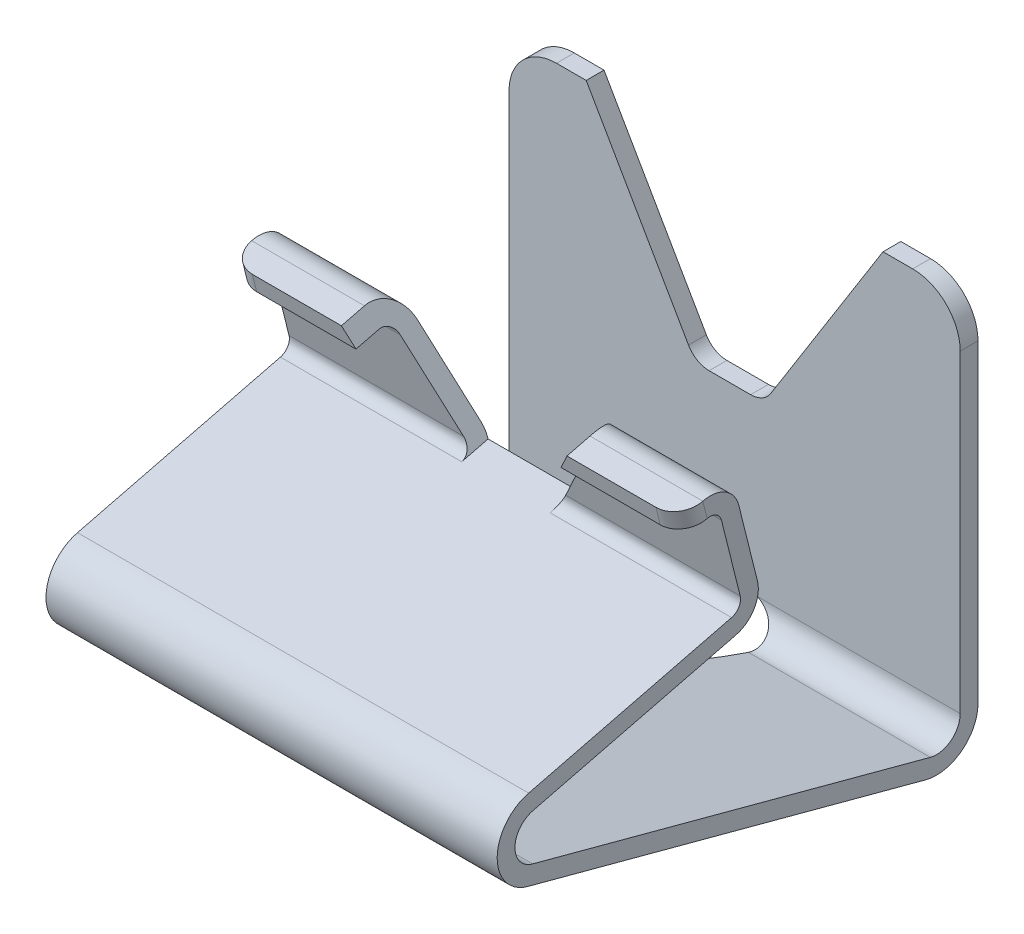
from build123d import *

# Parameters (mm, degrees)
BOSS_EXTRUDE1_DEPTH     = 38
FILLET1_R               = 4
FILLET2_R               = 8
CUT_EXTRUDE1_DEPTH      = 1
CUT_EXTRUDE1_DEPTH_BACK = 13
FILLET3_R               = 4
SKETCH4_R               = 8
CUT_EXTRUDE4_DEPTH      = 82.000266539
CUT_EXTRUDE5_DEPTH      = 51.051633202
CUT_EXTRUDE5_DEPTH_BACK = 45.963614062


with BuildPart() as part:
    # Sketch1 → Boss-Extrude1 (new body, symmetric)
    with BuildSketch(Plane.YZ):
        with BuildLine():
            Line((9.12257761, 0), (70, 0))
            Line((70, 0), (70, 3))
            Line((70, 3), (9.12257761, 3))
            ThreePointArc((9.12257761, 3), (5.949164249, 4.564954284), (5.258874305, 8.03527618))
            Line((5.258874305, 8.03527618), (23.211541616, 75.035542719))
            ThreePointArc((23.211541616, 75.035542719), (27.110151064, 78.000114231), (30.956427827, 74.967954121))
            Line((30.956427827, 74.967954121), (39.477634655, 40.791260242))
            ThreePointArc((39.477634655, 40.791260242), (41.753922912, 37.715033217), (45.538722765, 37.149391089))
            Line((45.538722765, 37.149391089), (58.152567206, 40.294375732))
            ThreePointArc((58.152567206, 40.294375732), (61.228794232, 42.570663989), (61.79443636, 46.355463841))
            Line((61.79443636, 46.355463841), (60.826748777, 50.236646746))
            Line((60.826748777, 50.236646746), (57.915861598, 49.510881059))
            Line((57.915861598, 49.510881059), (58.883549181, 45.629698154))
            ThreePointArc((58.883549181, 45.629698154), (58.65729233, 44.115778213), (57.426801519, 43.205262911))
            Line((57.426801519, 43.205262911), (44.812957078, 40.060278268))
            ThreePointArc((44.812957078, 40.060278268), (43.299037137, 40.286535119), (42.388521834, 41.517025929))
            Line((42.388521834, 41.517025929), (33.867315005, 75.693719808))
            ThreePointArc((33.867315005, 75.693719808), (27.13633067, 81), (20.313764138, 75.811999854))
            Line((20.313764138, 75.811999854), (2.361096826, 8.811733316))
            ThreePointArc((2.361096826, 8.811733316), (3.569104228, 2.738669997), (9.12257761, 0))
        make_face()
    extrude(amount=BOSS_EXTRUDE1_DEPTH, both=True)

    # Fillet1
    fillet1_edges = [part.edges().sort_by_distance(p)[0] for p in [
        (-38, 59.371305188, 49.873763903),
        (38, 59.371305188, 49.873763903),
    ]]
    fillet(fillet1_edges, radius=FILLET1_R)

    # Fillet2
    fillet2_edges = [part.edges().sort_by_distance(p)[0] for p in [
        (-38, 70, 1.5),
        (38, 70, 1.5),
    ]]
    fillet(fillet2_edges, radius=FILLET2_R)

    # Sketch2 → Cut-Extrude1 (cut, two sides)
    with BuildSketch(Plane(origin=(0, 0, 0), x_dir=(1, 0, 0), z_dir=(0, 0, -1))) as cut_extrude1_sk:
        Polygon((-25, -70), (-6.612779769, -38), (4.912194323, -38), (25, -70), align=None)
    extrude(amount=CUT_EXTRUDE1_DEPTH, mode=Mode.SUBTRACT)
    extrude(cut_extrude1_sk.sketch, amount=-CUT_EXTRUDE1_DEPTH_BACK, mode=Mode.SUBTRACT)

    # Fillet3
    fillet3_edges = [part.edges().sort_by_distance(p)[0] for p in [
        (4.912194323, 38, 1.5),
        (-6.612779769, 38, 1.5),
    ]]
    fillet(fillet3_edges, radius=FILLET3_R)

    # Sketch4 → Cut-Extrude4 (cut, through all)
    with BuildSketch(Plane(origin=(0, 0, 0), x_dir=(1, 0, 0), z_dir=(0, 0, -1))):
        with Locations((0, -2.12257761)):
            Circle(SKETCH4_R)
    extrude(amount=-CUT_EXTRUDE4_DEPTH, mode=Mode.SUBTRACT)

    # Sketch6 → Cut-Extrude5 (cut, two sides)
    with BuildSketch(Plane(origin=(0, -6.780848473, 27.196497771), x_dir=(1, 0, 0), z_dir=(0, -0.241921896, 0.970295726))) as cut_extrude5_sk:
        Polygon((-19, 71.173279191), (-7.452994616, 51.173279191), (7.452994616, 51.173279191), (19, 71.173279191), align=None)
    extrude(amount=CUT_EXTRUDE5_DEPTH, mode=Mode.SUBTRACT)
    extrude(cut_extrude5_sk.sketch, amount=-CUT_EXTRUDE5_DEPTH_BACK, mode=Mode.SUBTRACT)


solid = part.part
